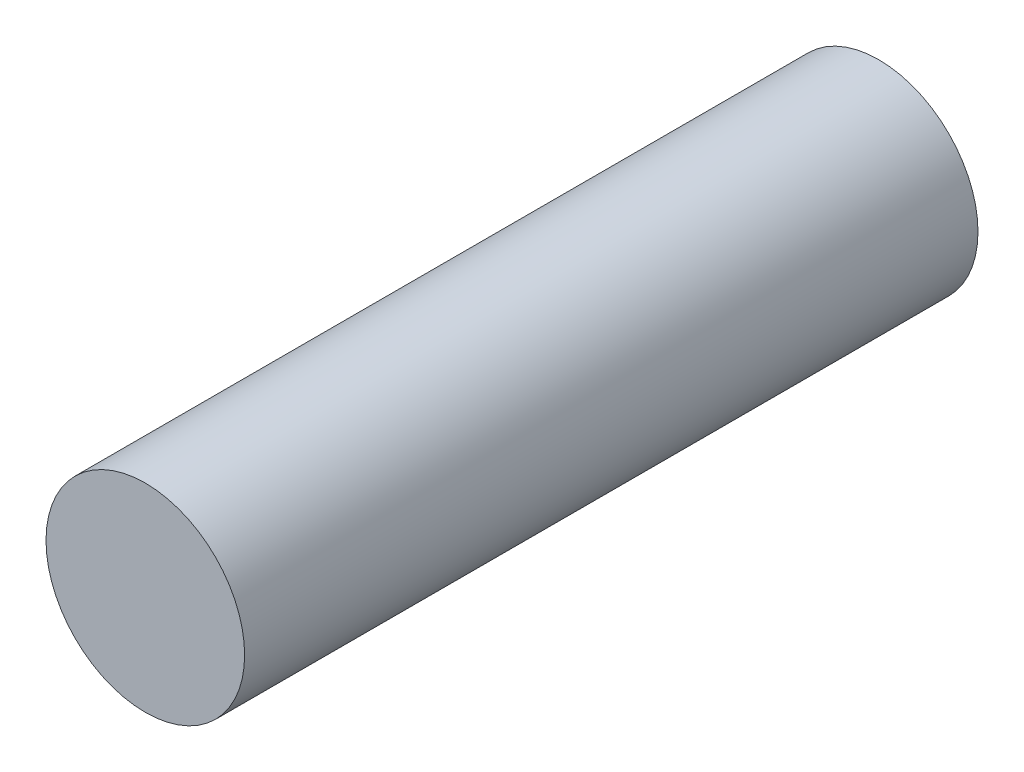
from build123d import *

# Parameters (mm, degrees)
SKETCH1_R           = 6.5
BOSS_EXTRUDE1_DEPTH = 24


with BuildPart() as part:
    # Sketch1 → Boss-Extrude1 (new body, symmetric)
    with BuildSketch(Plane.XY):
        Circle(SKETCH1_R)
    extrude(amount=BOSS_EXTRUDE1_DEPTH, both=True)


solid = part.part
